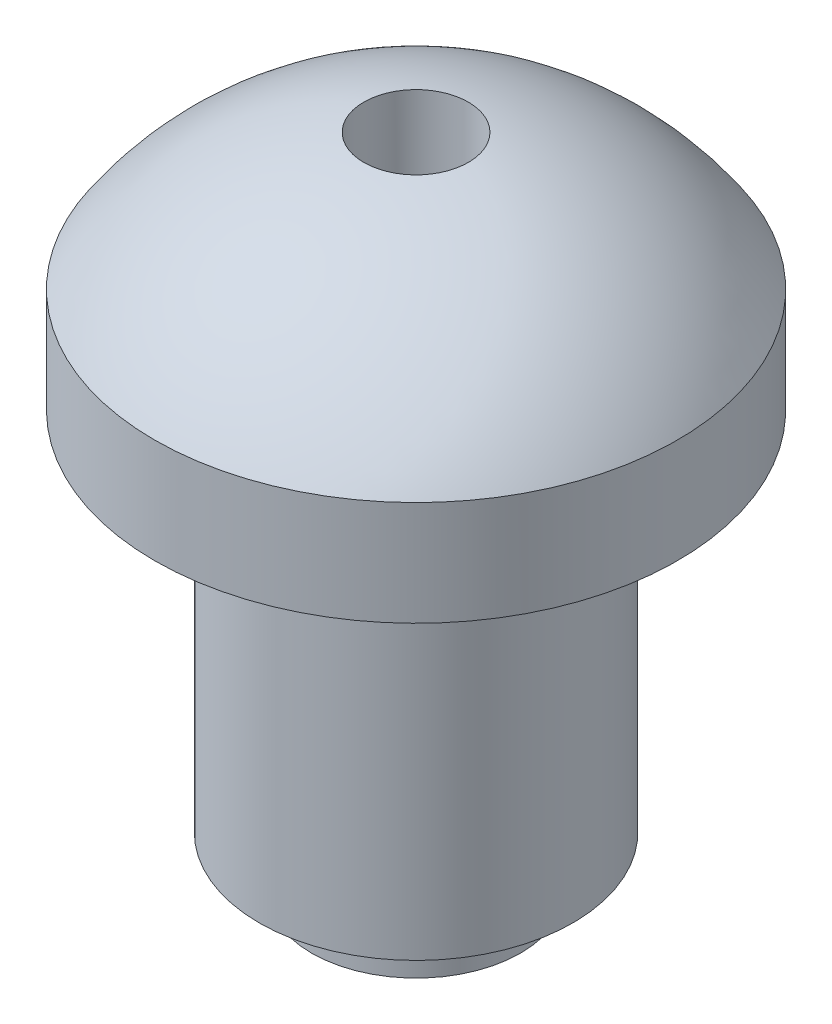
from build123d import *

# Parameters (mm, degrees)
SKETCH1_W = 2
SKETCH1_H = 1


with BuildPart() as part:
    # Sketch1 → Revolve2 (revolve)
    with BuildSketch(Plane.XY, mode=Mode.PRIVATE) as revolve2_sk:
        with Locations((-1, -0.5)):
            Rectangle(SKETCH1_W, SKETCH1_H)
        Polygon((0, 0), (0, 7), (-3, 7), (-3, 0), (-2, 0), align=None)
        Polygon((0, 7), (0, 9), (-5, 9), (-5, 7), (-3, 7), align=None)
        with BuildLine():
            Line((0, 9), (0, 9.68337521))
            Line((0, 9.68337521), (-1, 9.68337521))
            Line((-1, 9.68337521), (-1, 11.599454993))
            ThreePointArc((-1, 11.599454993), (-3.269448205, 10.714350109), (-5, 9))
            Line((-5, 9), (0, 9))
        make_face()
    revolve(revolve2_sk.sketch.rotate(Axis((0, 85.082557183, 0), (0, -1, 0)), 270), axis=Axis((0, 85.082557183, 0), (0, -1, 0)))


solid = part.part
